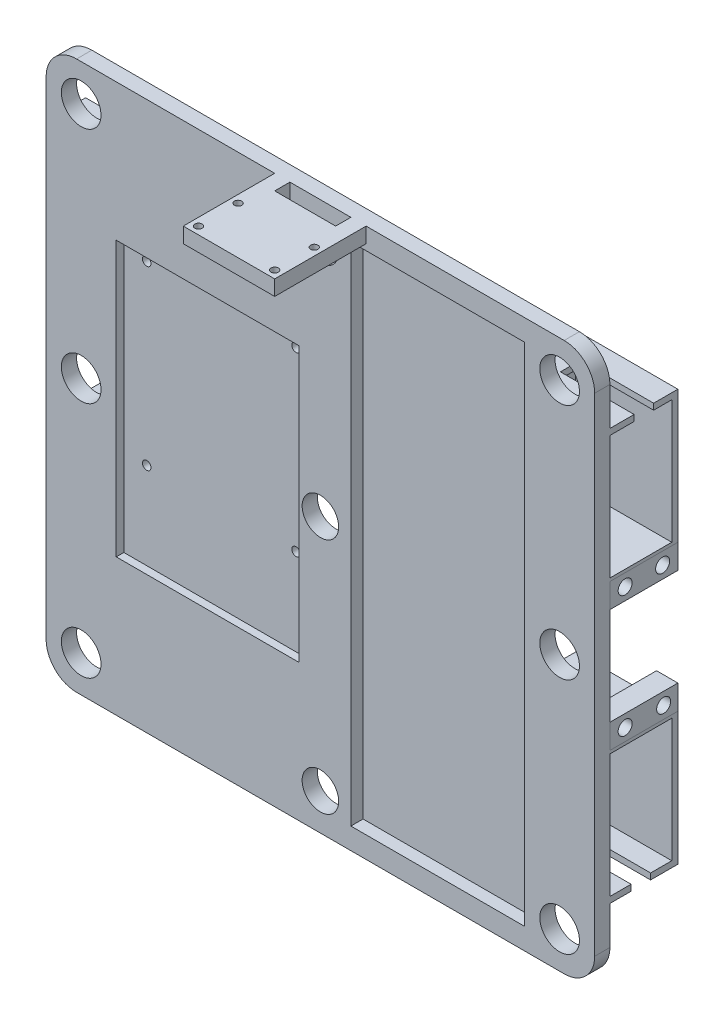
from build123d import *

# Parameters (mm, degrees)
SKETCH1_W             = 180
SKETCH1_H             = 180
BOSS_EXTRUDE1_DEPTH   = 5
SKETCH2_W             = 60
SKETCH2_H             = 90
CUT_EXTRUDE1_DEPTH    = 2.5
SKETCH3_R             = 1.4
CUT_EXTRUDE2_DEPTH    = 2.5
SKETCH4_W             = 57
SKETCH4_H             = 166
CUT_EXTRUDE3_DEPTH    = 4
BOSS_EXTRUDE2_DEPTH   = 20.3
SKETCH7_W             = 33.6
SKETCH7_H             = 43.5
BOSS_EXTRUDE3_DEPTH   = 2
SKETCH8_W             = 6.4
SKETCH8_H             = 2
CUT_EXTRUDE5_DEPTH    = 24.2
SKETCH9_W             = 22.3
SKETCH9_H             = 8
BOSS_EXTRUDE4_DEPTH   = 7
BOSS_EXTRUDE4_2_DEPTH = 7
SKETCH12_W            = 22.3
SKETCH12_H            = 8
BOSS_EXTRUDE5_DEPTH   = 7
SKETCH11_W            = 6.4
SKETCH11_H            = 2
CUT_EXTRUDE7_DEPTH    = 24.2
SKETCH10_R            = 2.3
CUT_EXTRUDE6_DEPTH    = 181
SKETCH13_R            = 6.5
SKETCH13_R_2          = 6
CUT_EXTRUDE8_DEPTH    = 28.3
FILLET1_R             = 10
BOSS_EXTRUDE6_DEPTH   = 5
SKETCH15_R            = 1.2
CUT_EXTRUDE9_DEPTH    = 181


with BuildPart() as part:
    # Sketch1 → Boss-Extrude1 (new body)
    with BuildSketch(Plane.XY):
        Rectangle(SKETCH1_W, SKETCH1_H)
    extrude(amount=BOSS_EXTRUDE1_DEPTH)

    # Sketch2 → Cut-Extrude1 (cut)
    with BuildSketch(Plane.XY.offset(5)):
        with Locations((-37, 0)):
            Rectangle(SKETCH2_W, SKETCH2_H)
    extrude(amount=-CUT_EXTRUDE1_DEPTH, mode=Mode.SUBTRACT)

    # Sketch3 → Cut-Extrude2 (cut)
    with BuildSketch(Plane.XY.offset(2.5)):
        with Locations((-10.5, 41.5)):
            Circle(SKETCH3_R)
        with Locations((-59.5, 41.5)):
            Circle(SKETCH3_R)
        with Locations((-59.5, -16.5)):
            Circle(SKETCH3_R)
        with Locations((-10.5, -16.5)):
            Circle(SKETCH3_R)
    extrude(amount=-CUT_EXTRUDE2_DEPTH, mode=Mode.SUBTRACT)

    # Sketch4 → Cut-Extrude3 (cut)
    with BuildSketch(Plane.XY.offset(5)):
        with Locations((38.5, 0)):
            Rectangle(SKETCH4_W, SKETCH4_H)
    extrude(amount=-CUT_EXTRUDE3_DEPTH, mode=Mode.SUBTRACT)

    # Sketch6 → Boss-Extrude2 (add)
    with BuildSketch(Plane(origin=(0, 0, 0), x_dir=(-1, 0, 0), z_dir=(0, 0, -1))):
        Polygon((90, 65.5), (58.4, 65.5), (58.4, 25), (90, 25), (90, 24), (56.4, 24), (56.4, 67.5), (90, 67.5), align=None)
        Polygon((90, -25), (58.4, -25), (58.4, -65.5), (90, -65.5), (90, -67.5), (56.4, -67.5), (56.4, -24), (90, -24), align=None)
        Polygon((-90, -25), (-58.4, -25), (-58.4, -65.5), (-90, -65.5), (-90, -67.5), (-56.4, -67.5), (-56.4, -24), (-90, -24), align=None)
        Polygon((-90, 65.5), (-58.4, 65.5), (-58.4, 25), (-90, 25), (-90, 24), (-56.4, 24), (-56.4, 67.5), (-90, 67.5), align=None)
    extrude(amount=BOSS_EXTRUDE2_DEPTH)

    # Sketch7 → Boss-Extrude3 (add)
    with BuildSketch(Plane(origin=(0, 0, -20.3), x_dir=(-1, 0, 0), z_dir=(0, 0, -1))):
        with Locations((-73.2, 45.75)):
            Rectangle(SKETCH7_W, SKETCH7_H)
        with Locations((-73.2, -45.75)):
            Rectangle(SKETCH7_W, SKETCH7_H)
        with Locations((73.2, -45.75)):
            Rectangle(SKETCH7_W, SKETCH7_H)
        with Locations((73.2, 45.75)):
            Rectangle(SKETCH7_W, SKETCH7_H)
    extrude(amount=BOSS_EXTRUDE3_DEPTH)

    # Sketch8 → Cut-Extrude5 (cut)
    with BuildSketch(Plane(origin=(90, 0, 0), x_dir=(0, 0, -1), z_dir=(1, 0, 0))):
        with Locations((10.15, -66.5)):
            Rectangle(SKETCH8_W, SKETCH8_H)
        with Locations((11.15, 66.5)):
            Rectangle(SKETCH8_W, SKETCH8_H)
    extrude(amount=-CUT_EXTRUDE5_DEPTH, mode=Mode.SUBTRACT)

    # Sketch12 → Boss-Extrude5 (add)
    with BuildSketch(Plane.ZY.offset(90)):
        with Locations((-11.15, 20)):
            Rectangle(SKETCH12_W, SKETCH12_H)
        with Locations((-11.15, -20)):
            Rectangle(SKETCH12_W, SKETCH12_H)
    extrude(amount=-BOSS_EXTRUDE5_DEPTH)

    # Sketch11 → Cut-Extrude7 (cut)
    with BuildSketch(Plane.ZY.offset(90)):
        with Locations((-11.15, 66.5)):
            Rectangle(SKETCH11_W, SKETCH11_H)
        with Locations((-10.15, -66.5)):
            Rectangle(SKETCH11_W, SKETCH11_H)
    extrude(amount=-CUT_EXTRUDE7_DEPTH, mode=Mode.SUBTRACT)


with BuildPart() as body_2:
    # Sketch9 → Boss-Extrude4 (new body)
    with BuildSketch(Plane(origin=(90, 0, 0), x_dir=(0, 0, -1), z_dir=(1, 0, 0))):
        with Locations((11.15, 20)):
            Rectangle(SKETCH9_W, SKETCH9_H)
    extrude(amount=-BOSS_EXTRUDE4_DEPTH)


with BuildPart() as body_3:
    # Sketch9 → Boss-Extrude4 2 (new body)
    with BuildSketch(Plane(origin=(90, 0, 0), x_dir=(0, 0, -1), z_dir=(1, 0, 0))):
        with Locations((11.15, -20)):
            Rectangle(SKETCH9_W, SKETCH9_H)
    extrude(amount=-BOSS_EXTRUDE4_2_DEPTH)


with BuildPart() as cut_extrude6_tool:
    # Sketch10 → Cut-Extrude6 (new body, through all)
    with BuildSketch(Plane(origin=(90, 0, 0), x_dir=(0, 0, -1), z_dir=(1, 0, 0))):
        with Locations((5, 20)):
            Circle(SKETCH10_R)
        with Locations((17.3, 20)):
            Circle(SKETCH10_R)
        with Locations((5, -20)):
            Circle(SKETCH10_R)
        with Locations((17.635342224, -20)):
            Circle(SKETCH10_R)
    extrude(amount=-CUT_EXTRUDE6_DEPTH)


with BuildPart() as part_1:
    add(part.part)

    # Cut-Extrude6: cut by cut_extrude6_tool
    add(cut_extrude6_tool.part, mode=Mode.SUBTRACT)

    # Sketch13 → Cut-Extrude8 (cut, through all)
    with BuildSketch(Plane.XY.offset(5)):
        with Locations((78.5, 78)):
            Circle(SKETCH13_R)
        with Locations((78.5, 0)):
            Circle(SKETCH13_R)
        with Locations((78.5, -78)):
            Circle(SKETCH13_R)
        with Locations((-78.5, 78)):
            Circle(SKETCH13_R)
        with Locations((-78.5, 0)):
            Circle(SKETCH13_R)
        with Locations((-78.5, -78)):
            Circle(SKETCH13_R)
        Circle(SKETCH13_R_2)
        with Locations((0, 78)):
            Circle(SKETCH13_R_2)
        with Locations((0, -78)):
            Circle(SKETCH13_R_2)
    extrude(amount=-CUT_EXTRUDE8_DEPTH, mode=Mode.SUBTRACT)

    # Fillet1
    fillet1_edges = [part_1.edges().sort_by_distance(p)[0] for p in [
        (-90, 90, 2.5),
        (90, 90, 2.5),
        (90, -90, 2.5),
        (-90, -90, 2.5),
    ]]
    fillet(fillet1_edges, radius=FILLET1_R)

    # Sketch14 → Boss-Extrude6 (add)
    with BuildSketch(Plane(origin=(0, 90, 0), x_dir=(1, 0, 0), z_dir=(0, 1, 0))):
        Polygon((-15, 0), (-15, -35), (15, -35), (15, 0), (10, 0), (10, -10), (-10, -10), (-10, 0), align=None)
    extrude(amount=-BOSS_EXTRUDE6_DEPTH)

    # Sketch15 → Cut-Extrude9 (cut, through all)
    with BuildSketch(Plane(origin=(0, 90, 0), x_dir=(1, 0, 0), z_dir=(0, 1, 0))):
        with Locations((-12.5, -32.5)):
            Circle(SKETCH15_R)
        with Locations((12.5, -32.5)):
            Circle(SKETCH15_R)
        with Locations((-12.5, -19.5)):
            Circle(SKETCH15_R)
        with Locations((12.5, -19.5)):
            Circle(SKETCH15_R)
    extrude(amount=-CUT_EXTRUDE9_DEPTH, mode=Mode.SUBTRACT)


with BuildPart() as body_2_1:
    add(body_2.part)

    # Cut-Extrude6: cut by cut_extrude6_tool
    add(cut_extrude6_tool.part, mode=Mode.SUBTRACT)


with BuildPart() as body_3_1:
    add(body_3.part)

    # Cut-Extrude6: cut by cut_extrude6_tool
    add(cut_extrude6_tool.part, mode=Mode.SUBTRACT)


solid = Compound([part_1.part, body_2_1.part, body_3_1.part])
